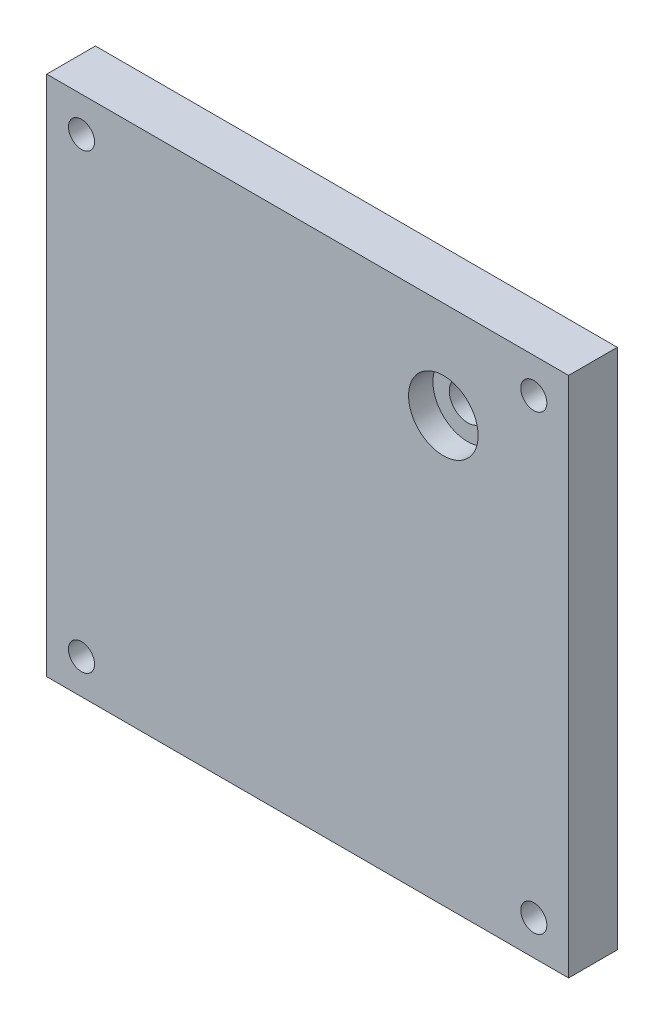
from build123d import *

# Parameters (mm, degrees)
SKETCH1_W           = 95.25
SKETCH1_H           = 95.25
BOSS_EXTRUDE1_DEPTH = 8.89
SKETCH2_OUTSIDE_W   = 124.25
SKETCH2_OUTSIDE_H   = 124.25
SKETCH2_OUTSIDE_W_2 = 95.25
SKETCH2_OUTSIDE_H_2 = 95.25
SKETCH2_OUTSIDE_R   = 2.38125
CUT_EXTRUDE2_DEPTH  = 9.89
SKETCH3_R           = 6.35
CUT_EXTRUDE3_DEPTH  = 4.445
SKETCH4_R           = 3.3655
CUT_EXTRUDE4_DEPTH  = 5.445


with BuildPart() as part:
    # Sketch1 → Boss-Extrude1 (new body)
    with BuildSketch(Plane.XY):
        Rectangle(SKETCH1_W, SKETCH1_H)
    extrude(amount=BOSS_EXTRUDE1_DEPTH)

    # Sketch2 outside → Cut-Extrude2 (cut, through all)
    with BuildSketch(Plane.XY.offset(8.89)):
        Rectangle(SKETCH2_OUTSIDE_W, SKETCH2_OUTSIDE_H)
        Rectangle(SKETCH2_OUTSIDE_W_2, SKETCH2_OUTSIDE_H_2, mode=Mode.SUBTRACT)
        with Locations((-41.275, 41.275)):
            Circle(SKETCH2_OUTSIDE_R)
        with Locations((41.275, 41.275)):
            Circle(SKETCH2_OUTSIDE_R)
        with Locations((41.275, -41.275)):
            Circle(SKETCH2_OUTSIDE_R)
        with Locations((-41.275, -41.275)):
            Circle(SKETCH2_OUTSIDE_R)
    extrude(amount=-CUT_EXTRUDE2_DEPTH, mode=Mode.SUBTRACT)

    # Sketch3 → Cut-Extrude3 (cut)
    with BuildSketch(Plane.XY.offset(8.89)):
        with Locations((24.765, 29.845)):
            Circle(SKETCH3_R)
    extrude(amount=-CUT_EXTRUDE3_DEPTH, mode=Mode.SUBTRACT)

    # Sketch4 → Cut-Extrude4 (cut, through all)
    with BuildSketch(Plane.XY.offset(4.445)):
        with Locations((24.765, 29.845)):
            Circle(SKETCH4_R)
    extrude(amount=-CUT_EXTRUDE4_DEPTH, mode=Mode.SUBTRACT)


solid = part.part
